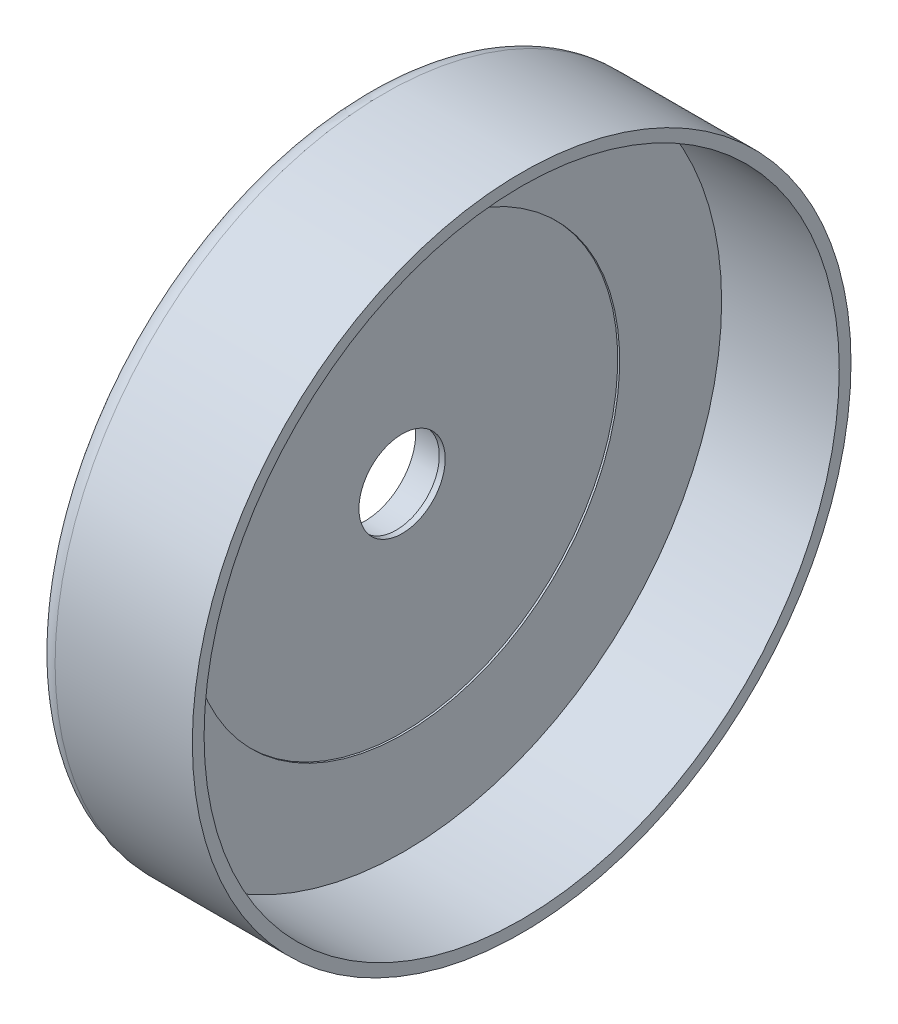
from build123d import *

# Parameters (mm, degrees)
FILLET1_R          = 5
SKETCH3_R          = 11
CUT_EXTRUDE2_DEPTH = 41
SKETCH6_W          = 0.5
SKETCH6_H          = 55
SKETCH9_R          = 13
CUT_EXTRUDE3_DEPTH = 8


with BuildPart() as part:
    # Sketch1 → Revolve1 (revolve)
    with BuildSketch(Plane.XY):
        Polygon((0, 0), (0, 81), (30, 81), (30, 84), (-10, 84), (-10, 0), align=None)
    revolve(axis=Axis((-10, 0, 0), (1, 0, 0)))

    # Fillet1
    fillet1_edges = [part.edges().sort_by_distance(p)[0] for p in [
        (-10, -84, 0),
    ]]
    fillet(fillet1_edges, radius=FILLET1_R)

    # Sketch3 → Cut-Extrude2 (cut, through all)
    with BuildSketch(Plane.ZY.offset(10)):
        Circle(SKETCH3_R)
    extrude(amount=-CUT_EXTRUDE2_DEPTH, mode=Mode.SUBTRACT)

    # Sketch6 → Cut-Revolve2 (revolve, cut)
    with BuildSketch(Plane.XY):
        with Locations((-0.25, 27.5)):
            Rectangle(SKETCH6_W, SKETCH6_H)
    revolve(axis=Axis((-10, 0, 0), (1, 0, 0)), mode=Mode.SUBTRACT)

    # Sketch9 → Cut-Extrude3 (cut)
    with BuildSketch(Plane.ZY.offset(10)):
        Circle(SKETCH9_R)
    extrude(amount=-CUT_EXTRUDE3_DEPTH, mode=Mode.SUBTRACT)


solid = part.part
